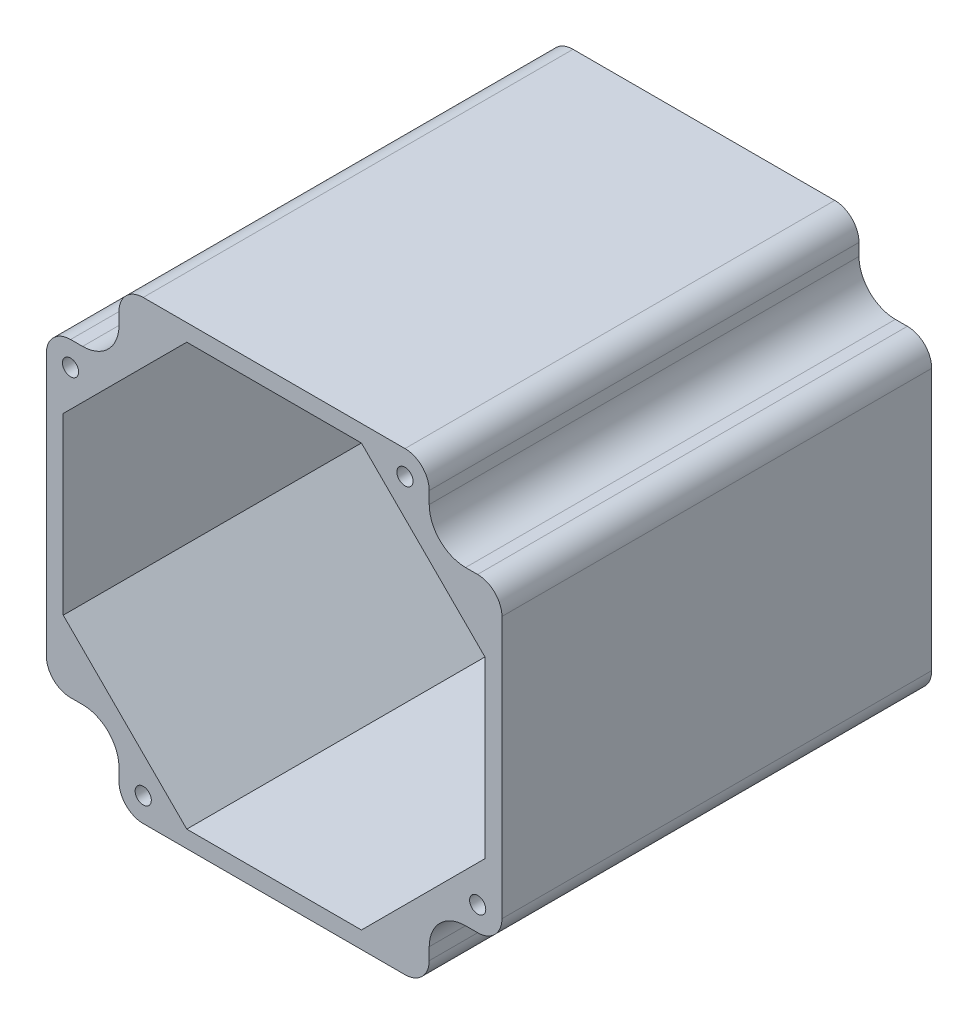
from build123d import *

# Parameters (mm, degrees)
SKETCH1_R           = 1
BOSS_EXTRUDE1_DEPTH = 53.2


with BuildPart() as part:
    # Sketch1 → Boss-Extrude1 (new body)
    with BuildSketch(Plane.XY):
        with BuildLine():
            Line((-23.7, 19.2), (-25.185156579, 19.199963279))
            ThreePointArc((-25.185156579, 19.199963279), (-27.316065894, 18.32656181), (-28.2, 16.2))
            Line((-28.2, 16.2), (-28.2, -16.2))
            ThreePointArc((-28.2, -16.2), (-27.316065894, -18.32656181), (-25.185156579, -19.199963279))
            Line((-25.185156579, -19.199963279), (-23.7, -19.2))
            ThreePointArc((-23.7, -19.2), (-20.518019485, -20.518019485), (-19.2, -23.7))
            Line((-19.2, -23.7), (-19.2, -25.2))
            ThreePointArc((-19.2, -25.2), (-18.321320344, -27.321320344), (-16.2, -28.2))
            Line((-16.2, -28.2), (16.2, -28.2))
            ThreePointArc((16.2, -28.2), (18.321320344, -27.321320344), (19.2, -25.2))
            Line((19.2, -25.2), (19.2, -23.7))
            ThreePointArc((19.2, -23.7), (20.518019485, -20.518019485), (23.7, -19.2))
            Line((23.7, -19.2), (25.185156579, -19.199963279))
            ThreePointArc((25.185156579, -19.199963279), (27.316065894, -18.32656181), (28.2, -16.2))
            Line((28.2, -16.2), (28.2, 16.2))
            ThreePointArc((28.2, 16.2), (27.316065894, 18.32656181), (25.185156579, 19.199963279))
            Line((25.185156579, 19.199963279), (23.7, 19.2))
            ThreePointArc((23.7, 19.2), (20.518019485, 20.518019485), (19.2, 23.7))
            Line((19.2, 23.7), (19.2, 25.2))
            ThreePointArc((19.2, 25.2), (18.321320344, 27.321320344), (16.2, 28.2))
            Line((16.2, 28.2), (-16.2, 28.2))
            ThreePointArc((-16.2, 28.2), (-18.321320344, 27.321320344), (-19.2, 25.2))
            Line((-19.2, 25.2), (-19.2, 23.7))
            ThreePointArc((-19.2, 23.7), (-20.518019485, 20.518019485), (-23.7, 19.2))
        make_face()
        with Locations((-25.2, 16.2)):
            Circle(SKETCH1_R, mode=Mode.SUBTRACT)
        with Locations((16.2, 25.2)):
            Circle(SKETCH1_R, mode=Mode.SUBTRACT)
        with Locations((25.2, -16.2)):
            Circle(SKETCH1_R, mode=Mode.SUBTRACT)
        with Locations((-16.2, -25.2)):
            Circle(SKETCH1_R, mode=Mode.SUBTRACT)
        Polygon((10.810973978, -26.1), (26.1, -10.810973978), (26.1, 10.810973978), (10.810973978, 26.1), (-10.810973978, 26.1), (-26.1, 10.810973978), (-26.1, -10.810973978), (-10.810973978, -26.1), align=None, mode=Mode.SUBTRACT)
    extrude(amount=BOSS_EXTRUDE1_DEPTH)


solid = part.part
